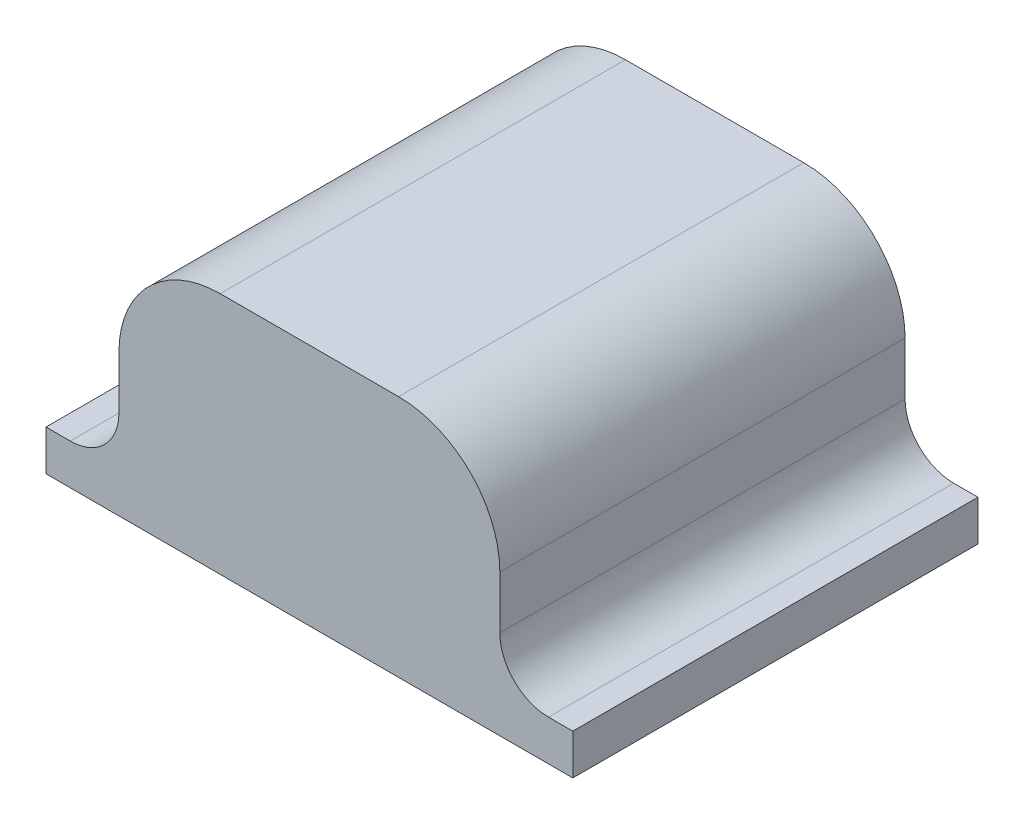
from build123d import *

# Parameters (mm, degrees)
EXTRUDE_1_DEPTH     = 50
CUT_EXTRUDE_START   = -3.2
CUT_EXTRUDE_1_DEPTH = 43.6
SKETCH_1_4_R        = 6
SKETCH_1_4_R_2      = 3.5
CUT_EXTRUDE_2_DEPTH = 10
SKETCH_3_R          = 9.5
SKETCH_3_R_2        = 3.5
EXTRUDE_3_DEPTH     = 6
SKETCH_3_3_R        = 6.5
CUT_EXTRUDE_3_DEPTH = 3
SKETCH_3_4_R        = 7
CUT_EXTRUDE_4_DEPTH = 0.75


with BuildPart() as part:
    # Эскиз1 → Бобышка-Вытянуть1 (new body)
    with BuildSketch(Plane.XY):
        with BuildLine():
            Line((0, 0), (0, 5))
            Line((0, 5), (3, 5))
            ThreePointArc((3, 5), (7.242640687, 6.757359313), (9, 11))
            Line((9, 11), (9, 17.5))
            ThreePointArc((9, 17.5), (12.661165235, 26.338834765), (21.5, 30))
            Line((21.5, 30), (43.5, 30))
            ThreePointArc((43.5, 30), (52.338834765, 26.338834765), (56, 17.5))
            Line((56, 17.5), (56, 11))
            ThreePointArc((56, 11), (57.757359313, 6.757359313), (62, 5))
            Line((62, 5), (65, 5))
            Line((65, 5), (65, 0))
            Line((65, 0), (0, 0))
        make_face()
    extrude(amount=EXTRUDE_1_DEPTH)

    # Эскиз2 → Вырез-Вытянуть1 (cut)
    with BuildSketch(Plane(origin=(0, 0, 0), x_dir=(-1, 0, 0), z_dir=(0, 0, -1)).offset(CUT_EXTRUDE_START)):
        with BuildLine():
            Line((-21.5, 27.6), (-43.5, 27.6))
            ThreePointArc((-43.5, 27.6), (-50.64177849, 24.64177849), (-53.6, 17.5))
            Line((-53.6, 17.5), (-53.6, 0))
            Line((-53.6, 0), (-11.4, 0))
            Line((-11.4, 0), (-11.4, 17.5))
            ThreePointArc((-11.4, 17.5), (-14.35822151, 24.64177849), (-21.5, 27.6))
        make_face()
    extrude(amount=-CUT_EXTRUDE_1_DEPTH, mode=Mode.SUBTRACT)

    # Эскиз1<4> → Вырез-Вытянуть2 (cut)
    with BuildSketch(Plane.XY):
        with Locations((21.5, 17.5)):
            Circle(SKETCH_1_4_R)
        with Locations((43.5, 17.5)):
            Circle(SKETCH_1_4_R_2)
    extrude(amount=CUT_EXTRUDE_2_DEPTH, mode=Mode.SUBTRACT)

    # Эскиз3 → Бобышка-Вытянуть3 (add)
    with BuildSketch(Plane(origin=(0, 0, 0), x_dir=(-1, 0, 0), z_dir=(0, 0, -1))):
        with Locations((-43.5, 17.5)):
            Circle(SKETCH_3_R)
        with Locations((-43.5, 17.5)):
            Circle(SKETCH_3_R_2, mode=Mode.SUBTRACT)
    extrude(amount=-EXTRUDE_3_DEPTH)

    # Эскиз3<3> → Вырез-Вытянуть3 (cut)
    with BuildSketch(Plane(origin=(0, 0, 0), x_dir=(-1, 0, 0), z_dir=(0, 0, -1))):
        with Locations((-43.5, 17.5)):
            Circle(SKETCH_3_3_R)
    extrude(amount=-CUT_EXTRUDE_3_DEPTH, mode=Mode.SUBTRACT)

    # Эскиз3<4> → Вырез-Вытянуть4 (cut)
    with BuildSketch(Plane(origin=(0, 0, 0), x_dir=(-1, 0, 0), z_dir=(0, 0, -1))):
        with Locations((-21.5, 17.5)):
            Circle(SKETCH_3_4_R)
    extrude(amount=-CUT_EXTRUDE_4_DEPTH, mode=Mode.SUBTRACT)


solid = part.part
